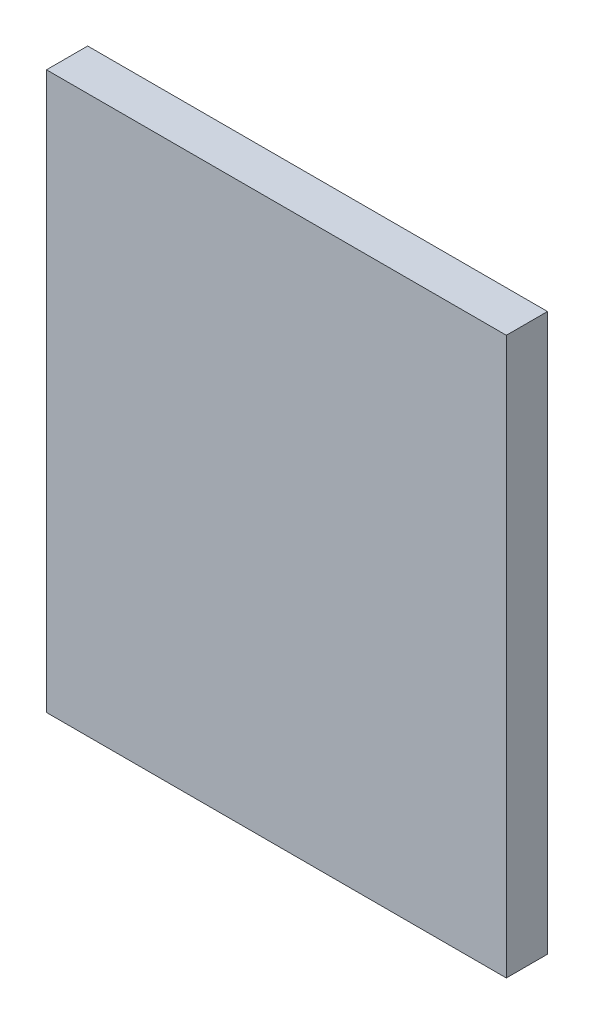
from build123d import *

# Parameters (mm, degrees)
SKETCH1_W           = 33.5
SKETCH1_H           = 40.55
BOSS_EXTRUDE1_DEPTH = 3


with BuildPart() as part:
    # Sketch1 → Boss-Extrude1 (new body)
    with BuildSketch(Plane.XY):
        with Locations((16.75, 20.275)):
            Rectangle(SKETCH1_W, SKETCH1_H)
    extrude(amount=BOSS_EXTRUDE1_DEPTH)


solid = part.part
